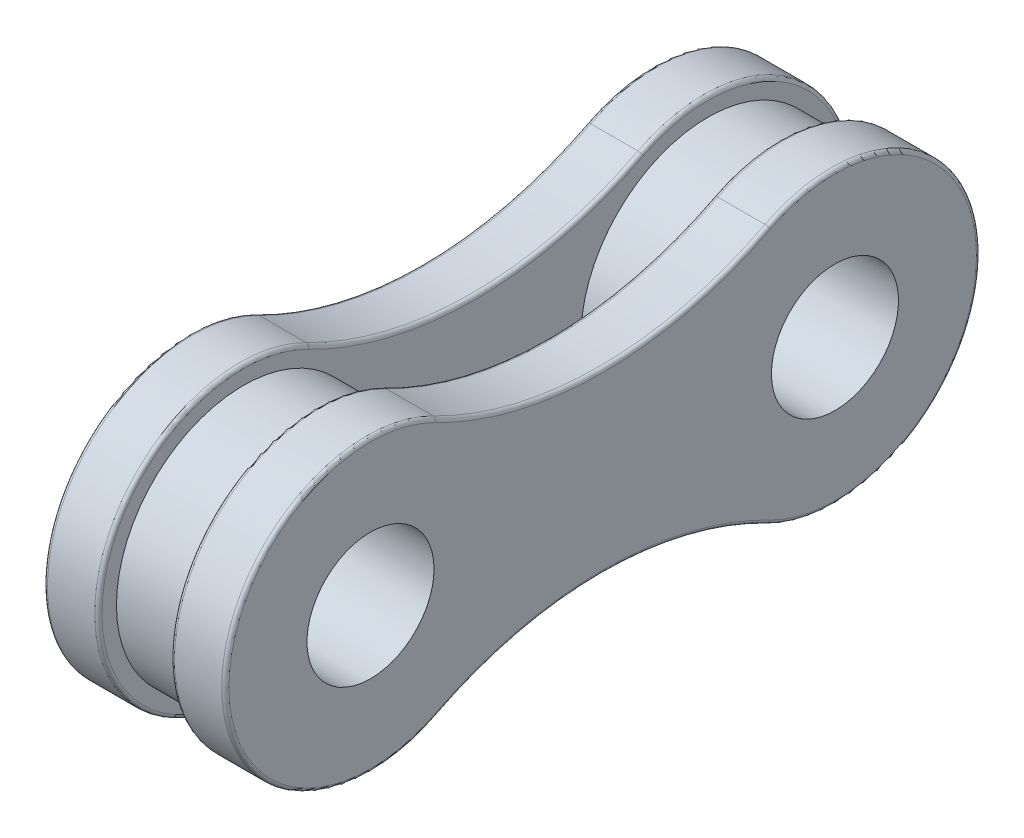
from build123d import *

# Parameters (mm, degrees)
BOSS_EXTRUDE1_START = 1
SKETCH1_R           = 1.75
BOSS_EXTRUDE1_DEPTH = 1.5
BOSS_EXTRUDE2_START = -1
SKETCH2_R           = 1.75
BOSS_EXTRUDE2_DEPTH = 1.5
SKETCH3_R           = 3.5
SKETCH3_R_2         = 1.75
BOSS_EXTRUDE3_DEPTH = 1
FILLET1_R           = 0.1


with BuildPart() as part:
    # Sketch1 → Boss-Extrude1 (new body)
    with BuildSketch(Plane(origin=(0, 0, 0), x_dir=(0, 0, -1), z_dir=(1, 0, 0)).offset(BOSS_EXTRUDE1_START)):
        with BuildLine():
            ThreePointArc((-4.570357143, 3.557793374), (-10.3985, 0), (-4.570357143, -3.557793374))
            ThreePointArc((-4.570357143, -3.557793374), (0, -2.45227681), (4.570357143, -3.557793374))
            ThreePointArc((4.570357143, -3.557793374), (10.3985, 0), (4.570357143, 3.557793374))
            ThreePointArc((4.570357143, 3.557793374), (0, 2.45227681), (-4.570357143, 3.557793374))
        make_face()
        with Locations((-6.3985, 0)):
            Circle(SKETCH1_R, mode=Mode.SUBTRACT)
        with Locations((6.3985, 0)):
            Circle(SKETCH1_R, mode=Mode.SUBTRACT)
    extrude(amount=BOSS_EXTRUDE1_DEPTH)



with BuildPart() as body_2:
    # Sketch2 → Boss-Extrude2 (new body)
    with BuildSketch(Plane(origin=(0, 0, 0), x_dir=(0, 0, -1), z_dir=(1, 0, 0)).offset(BOSS_EXTRUDE2_START)):
        with BuildLine():
            ThreePointArc((4.570357143, -3.557793374), (0, -2.45227681), (-4.570357143, -3.557793374))
            ThreePointArc((-4.570357143, -3.557793374), (-10.3985, 0), (-4.570357143, 3.557793374))
            ThreePointArc((-4.570357143, 3.557793374), (0, 2.45227681), (4.570357143, 3.557793374))
            ThreePointArc((4.570357143, 3.557793374), (10.3985, 0), (4.570357143, -3.557793374))
        make_face()
        with Locations((-6.3985, 0)):
            Circle(SKETCH2_R, mode=Mode.SUBTRACT)
        with Locations((6.3985, 0)):
            Circle(SKETCH2_R, mode=Mode.SUBTRACT)
    extrude(amount=-BOSS_EXTRUDE2_DEPTH)


with BuildPart() as part_1:
    add(part.part)

    add(body_2.part)  # Boss-Extrude3 merges body 2
    # Sketch3 → Boss-Extrude3 (add, symmetric)
    with BuildSketch(Plane(origin=(0, 0, 0), x_dir=(0, 0, -1), z_dir=(1, 0, 0))):
        with Locations((6.3985, 0)):
            Circle(SKETCH3_R)
        with Locations((6.3985, 0)):
            Circle(SKETCH3_R_2, mode=Mode.SUBTRACT)
        with Locations((-6.3985, 0)):
            Circle(SKETCH3_R)
        with Locations((-6.3985, 0)):
            Circle(SKETCH3_R_2, mode=Mode.SUBTRACT)
    extrude(amount=BOSS_EXTRUDE3_DEPTH, both=True)

    # Fillet1
    fillet1_edges = [part_1.edges().sort_by_distance(p)[0] for p in [
        (2.5, 2.45227681, 0),
        (2.5, 0, 10.3985),
        (-2.5, 0, -10.3985),
        (-2.5, -2.45227681, 0),
        (-2.5, 0, 10.3985),
        (-2.5, 2.45227681, 0),
        (-1, 0, -10.3985),
        (-1, 2.45227681, 0),
        (-1, 0, 10.3985),
        (-1, -2.45227681, 0),
        (2.5, -2.45227681, 0),
        (1, 0, 10.3985),
        (1, 2.45227681, 0),
        (1, 0, -10.3985),
        (1, -2.45227681, 0),
        (2.5, 0, -10.3985),
    ]]
    fillet(fillet1_edges, radius=FILLET1_R)


solid = part_1.part
